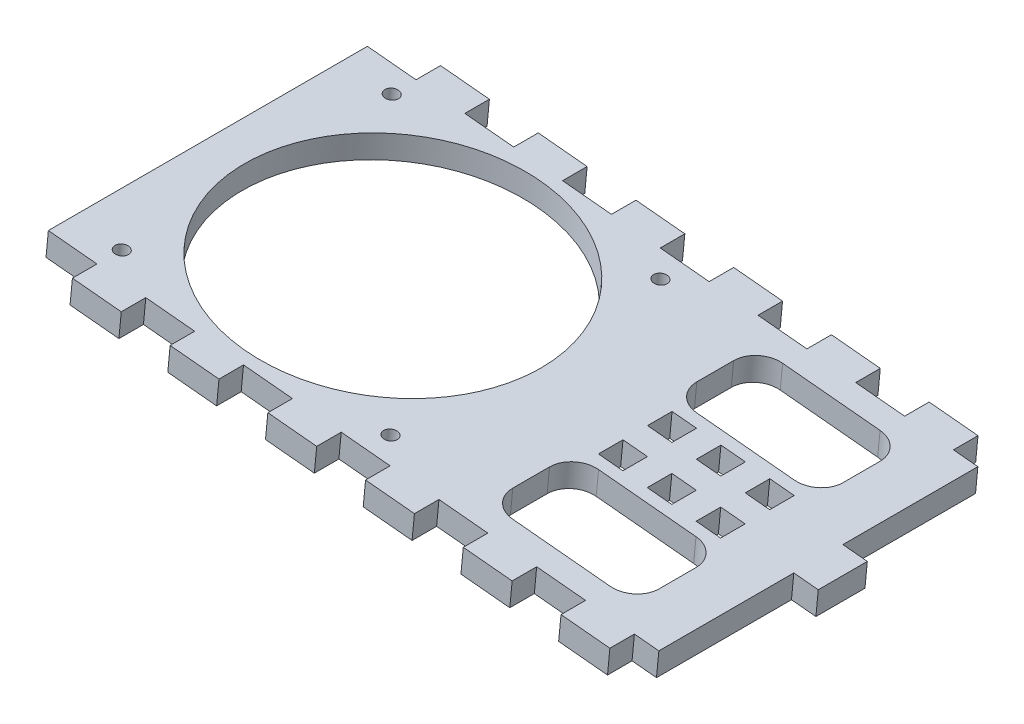
from build123d import *

# Parameters (mm, degrees)
BOSS_EXTRUDE1_DEPTH = 95.25
SKETCH3_RX          = 38.550537557
SKETCH3_RY          = 38.1
CUT_EXTRUDE1_DEPTH  = 23.094676213
SKETCH4_R           = 1.75
CUT_EXTRUDE2_DEPTH  = 23.094676322
SKETCH5_W           = 38.030754259
SKETCH5_H           = 69.85
CUT_EXTRUDE3_DEPTH  = 23.094676322
SKETCH7_W           = 12.7
SKETCH7_H           = 6.35
CUT_EXTRUDE4_DEPTH  = 23.094676322
LPATTERN1_COUNT     = 17
LPATTERN1_PITCH     = 25.4
SKETCH8_W           = 6.35
SKETCH8_H           = 34.925
CUT_EXTRUDE5_DEPTH  = 23.094676322
SKETCH9_W           = 38.030754259
SKETCH9_H           = 25.4
BOSS_EXTRUDE2_DEPTH = 6.35
SKETCH10_W          = 6.35
SKETCH10_H          = 6.35
CUT_EXTRUDE6_DEPTH  = 23.094676322
LPATTERN2_COUNT     = 2
LPATTERN2_PITCH     = 12.7
LPATTERN2_COL_COUNT = 2
LPATTERN2_COL_PITCH = 12.7
FILLET1_R           = 6.35


with BuildPart() as part:
    # Sketch2 → Boss-Extrude1 (new body)
    with BuildSketch(Plane.XY):
        Polygon((-127.443127302, 332.037142994), (-128.051747831, 325.716377135), (36.219237573, 309.898880304), (36.827858101, 316.219646163), align=None)
    extrude(amount=BOSS_EXTRUDE1_DEPTH)

    # Sketch3 → Cut-Extrude1 (cut, through all)
    with BuildSketch(Plane(origin=(30.507092242, 316.828266692, 0), x_dir=(0.995396198, -0.095845753, 0), z_dir=(0.095845753, 0.995396198, 0))):
        with Locations((-110.605216702, -47.625)):
            Ellipse(SKETCH3_RX, SKETCH3_RY)
    extrude(amount=-CUT_EXTRUDE1_DEPTH, mode=Mode.SUBTRACT)

    # Sketch4 → Cut-Extrude2 (cut, through all)
    with BuildSketch(Plane(origin=(30.507092242, 316.828266692, 0), x_dir=(0.995396198, -0.095845753, 0), z_dir=(0.095845753, 0.995396198, 0))):
        with Locations((-145.980754259, -12.7)):
            Circle(SKETCH4_R)
        with Locations((-145.980754259, -82.55)):
            Circle(SKETCH4_R)
        with Locations((-76.130754259, -82.55)):
            Circle(SKETCH4_R)
        with Locations((-76.130754259, -12.7)):
            Circle(SKETCH4_R)
    extrude(amount=-CUT_EXTRUDE2_DEPTH, mode=Mode.SUBTRACT)

    # Sketch5 → Cut-Extrude3 (cut, through all)
    with BuildSketch(Plane(origin=(30.507092242, 316.828266692, 0), x_dir=(0.995396198, -0.095845753, 0), z_dir=(0.095845753, 0.995396198, 0))):
        with Locations((-31.71537713, -47.625)):
            Rectangle(SKETCH5_W, SKETCH5_H)
    extrude(amount=-CUT_EXTRUDE3_DEPTH, mode=Mode.SUBTRACT)

    # Sketch7 → Cut-Extrude4 (cut, through all)
    with BuildSketch(Plane(origin=(30.507092242, 316.828266692, 0), x_dir=(0.995396198, -0.095845753, 0), z_dir=(0.095845753, 0.995396198, 0))):
        with Locations((0, -3.175)):
            Rectangle(SKETCH7_W, SKETCH7_H)
        with Locations((0, -92.075)):
            Rectangle(SKETCH7_W, SKETCH7_H)
    cut_extrude4 = extrude(amount=-CUT_EXTRUDE4_DEPTH, mode=Mode.SUBTRACT)

    # LPattern1: Cut-Extrude4 ×17
    with Locations(*[Vector(-0.995396198, 0.095845753, 0) * (i * LPATTERN1_PITCH) for i in range(1, LPATTERN1_COUNT)]):
        add(cut_extrude4, mode=Mode.SUBTRACT)

    # Sketch8 → Cut-Extrude5 (cut, through all)
    with BuildSketch(Plane(origin=(30.507092242, 316.828266692, 0), x_dir=(0.995396198, -0.095845753, 0), z_dir=(0.095845753, 0.995396198, 0))):
        with Locations((3.175, -23.8125)):
            Rectangle(SKETCH8_W, SKETCH8_H)
        with Locations((3.175, -71.4375)):
            Rectangle(SKETCH8_W, SKETCH8_H)
    extrude(amount=-CUT_EXTRUDE5_DEPTH, mode=Mode.SUBTRACT)

    # Sketch9 → Boss-Extrude2 (add)
    with BuildSketch(Plane(origin=(30.507092242, 316.828266692, 0), x_dir=(0.995396198, -0.095845753, 0), z_dir=(0.095845753, 0.995396198, 0))):
        with Locations((-31.71537713, -47.625)):
            Rectangle(SKETCH9_W, SKETCH9_H)
    extrude(amount=-BOSS_EXTRUDE2_DEPTH)

    # Sketch10 → Cut-Extrude6 (cut, through all)
    with BuildSketch(Plane(origin=(30.507092242, 316.828266692, 0), x_dir=(0.995396198, -0.095845753, 0), z_dir=(0.095845753, 0.995396198, 0))):
        with Locations((-31.71537713, -41.275)):
            Rectangle(SKETCH10_W, SKETCH10_H)
        with Locations((-31.71537713, -53.975)):
            Rectangle(SKETCH10_W, SKETCH10_H)
    cut_extrude6 = extrude(amount=-CUT_EXTRUDE6_DEPTH, mode=Mode.SUBTRACT)

    # LPattern2: Cut-Extrude6 ×2
    with Locations(*[Vector(0.995396198, -0.095845753, 0) * (i * LPATTERN2_PITCH) for i in range(1, LPATTERN2_COUNT)]):
        add(cut_extrude6, mode=Mode.SUBTRACT)

    # LPattern2 col: Cut-Extrude6 ×2
    with Locations(*[Vector(-0.995396198, 0.095845753, 0) * (i * LPATTERN2_COL_PITCH) for i in range(1, LPATTERN2_COL_COUNT)]):
        add(cut_extrude6, mode=Mode.SUBTRACT)

    # Fillet1
    fillet1_edges = [part.edges().sort_by_distance(p)[0] for p in [
        (17.561250258, 314.885124819, 34.925),
        (17.561250258, 314.885124819, 60.325),
        (-20.294417953, 318.53021108, 60.325),
        (-20.294417953, 318.53021108, 34.925),
        (-20.294417953, 318.53021108, 82.55),
        (-20.294417953, 318.53021108, 12.7),
        (17.561250258, 314.885124819, 12.7),
        (17.561250258, 314.885124819, 82.55),
    ]]
    fillet(fillet1_edges, radius=FILLET1_R)


solid = part.part
